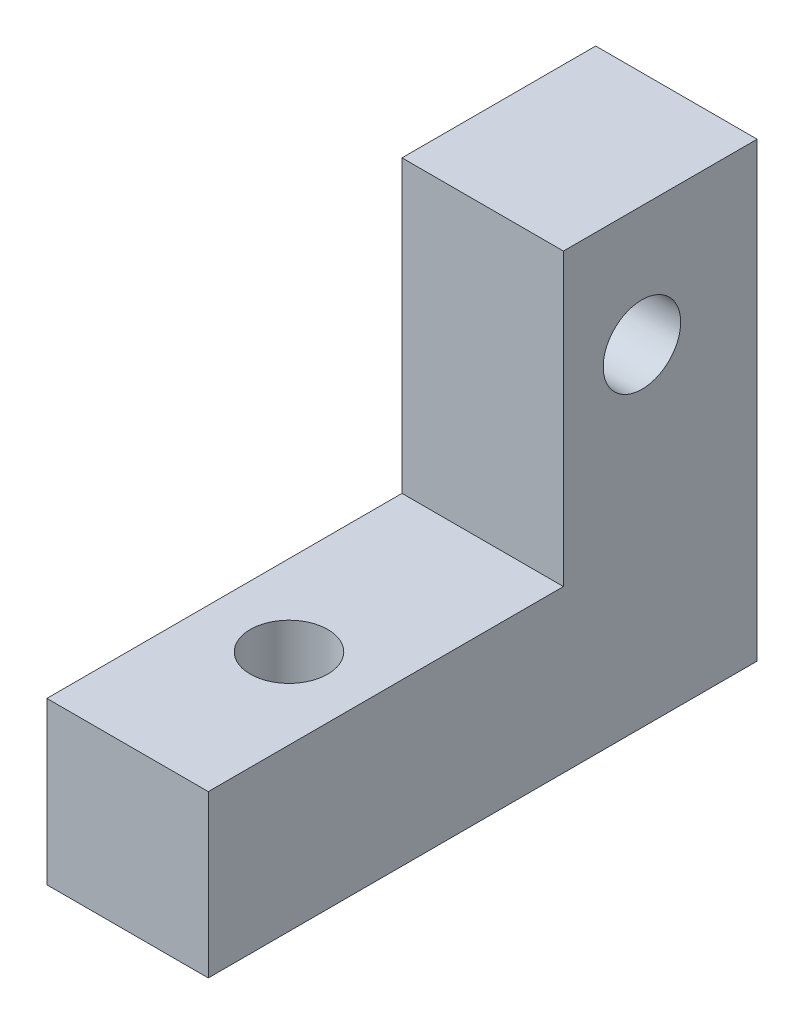
from build123d import *

# Parameters (mm, degrees)
BOSS_EXTRUDE1_DEPTH = 6.35
SKETCH4_R           = 1.524
CUT_EXTRUDE1_DEPTH  = 6.35
SKETCH5_R           = 1.524
CUT_EXTRUDE3_DEPTH  = 7.35


with BuildPart() as part:
    # Sketch3 → Boss-Extrude1 (new body)
    with BuildSketch(Plane(origin=(0, 0, 0), x_dir=(0, 0, -1), z_dir=(1, 0, 0))):
        Polygon((0, 0), (0, 6.35), (13.97, 6.35), (13.97, 17.78), (21.59, 17.78), (21.59, 0), align=None)
    extrude(amount=BOSS_EXTRUDE1_DEPTH)

    # Sketch4 → Cut-Extrude1 (cut)
    with BuildSketch(Plane(origin=(0, 6.35, 0), x_dir=(1, 0, 0), z_dir=(0, 1, 0))):
        with Locations((3.175, 6.35)):
            Circle(SKETCH4_R)
    extrude(amount=-CUT_EXTRUDE1_DEPTH, mode=Mode.SUBTRACT)

    # Sketch5 → Cut-Extrude3 (cut, through all)
    with BuildSketch(Plane(origin=(6.35, 0, 0), x_dir=(0, 0, -1), z_dir=(1, 0, 0))):
        with Locations((17.057623492, 13.051566734)):
            Circle(SKETCH5_R)
    extrude(amount=-CUT_EXTRUDE3_DEPTH, mode=Mode.SUBTRACT)


solid = part.part
